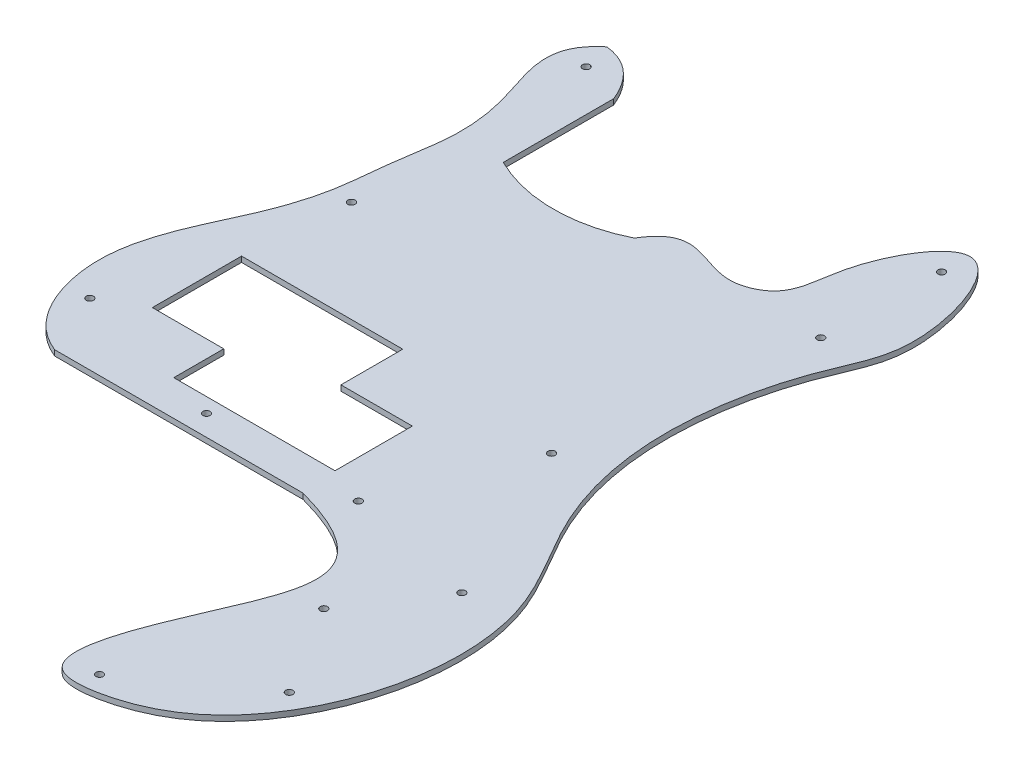
from build123d import *

# Parameters (mm, degrees)
SKETCH1_R           = 1.6764
BOSS_EXTRUDE1_DEPTH = 2.54
CUT_EXTRUDE1_DEPTH  = 3.5400001


with BuildPart() as part:
    # Sketch1 → Boss-Extrude1 (new body)
    with BuildSketch(Plane(origin=(0, 0, 0), x_dir=(1, 0, 0), z_dir=(0, 1, 0))):
        with BuildLine():
            add(Edge.make_bspline(
                [(0, 0), (-11.530009109, 4.514458613), (-23.598116483, 21.764864338), (-27.141921833, 51.196086815), (-19.613077512, 77.06977201), (-7.49782478, 100.945161618), (1.098739727, 126.482448194), (2.538563392, 152.451362426), (7.778248397, 177.773773965), (3.499596198, 210.514145227), (-10.048019094, 234.324881398), (6.35, 247.65)],
                knots=[0, 0, 0, 0, 0.130338526, 0.226963598, 0.325793327, 0.430446663, 0.530898137, 0.627523208, 0.72414828, 0.820773351, 1, 1, 1, 1], degree=3))
            Line((0, 0), (114.3, 0))
            add(Edge.make_bspline(
                [(114.3, 0), (170.623192114, -15.324499827), (142.778538688, -51.014826152), (117.072370085, -130.865354033), (166.910373227, -124.747305796), (211.270043304, -85.648094536), (223.254152949, -5.84316241), (185.826230854, 45.08468032), (168.892743993, 100.701866142), (177.456556308, 154.68299123), (201.016482927, 201.558360826), (177.939980571, 271.837359168), (147.118130497, 218.1362838), (148.128075893, 189.829801963), (118.716390008, 176.497868685), (100.979559676, 198.210582651), (88.9, 177.8)],
                knots=[0, 0, 0, 0, 0.148092664, 0.210362687, 0.240168738, 0.321979976, 0.461111394, 0.528032739, 0.586689278, 0.706181911, 0.74268238, 0.823050716, 0.881913078, 0.917688905, 0.939312918, 1, 1, 1, 1], degree=3))
            ThreePointArc((88.9, 177.8), (58.7375, 170.688), (28.575, 177.8))
            Line((28.575, 177.8), (28.575, 228.6))
            add(Edge.make_bspline(
                [(6.35, 247.65), (21.424126315, 246.030027347), (28.575, 228.6)],
                knots=[0, 0, 0, 1, 1, 1], degree=2))
        make_face()
        with Locations((-12.3825, 28.575)):
            Circle(SKETCH1_R, mode=Mode.SUBTRACT)
        with Locations((60.325, 9.525)):
            Circle(SKETCH1_R, mode=Mode.SUBTRACT)
        with Locations((139.7, -119.0625)):
            Circle(SKETCH1_R, mode=Mode.SUBTRACT)
        with Locations((190.5, -82.55)):
            Circle(SKETCH1_R, mode=Mode.SUBTRACT)
        with Locations((165.1, -41.275)):
            Circle(SKETCH1_R, mode=Mode.SUBTRACT)
        with Locations((130.175, 9.525)):
            Circle(SKETCH1_R, mode=Mode.SUBTRACT)
        with Locations((190.5, -3.175)):
            Circle(SKETCH1_R, mode=Mode.SUBTRACT)
        with Locations((9.525, 127)):
            Circle(SKETCH1_R, mode=Mode.SUBTRACT)
        with Locations((9.525, 234.95)):
            Circle(SKETCH1_R, mode=Mode.SUBTRACT)
        with Locations((155.575, 73.025)):
            Circle(SKETCH1_R, mode=Mode.SUBTRACT)
        with Locations((171.45, 180.975)):
            Circle(SKETCH1_R, mode=Mode.SUBTRACT)
        with Locations((173.0375, 234.95)):
            Circle(SKETCH1_R, mode=Mode.SUBTRACT)
    extrude(amount=BOSS_EXTRUDE1_DEPTH)

    # Sketch2 → Cut-Extrude1 (cut, through all)
    with BuildSketch(Plane(origin=(0, 2.54, 0), x_dir=(1, 0, 0), z_dir=(0, 1, 0))):
        Polygon((38.545976824, 16.256), (112.709798919, 16.256), (112.709798919, 51.837996649), (79.86163156, 51.837996649), (79.86163156, 80.270361379), (5.697809465, 80.270361379), (5.697809465, 39.243531431), (38.545976824, 39.243531431), align=None)
    extrude(amount=-CUT_EXTRUDE1_DEPTH, mode=Mode.SUBTRACT)


solid = part.part
